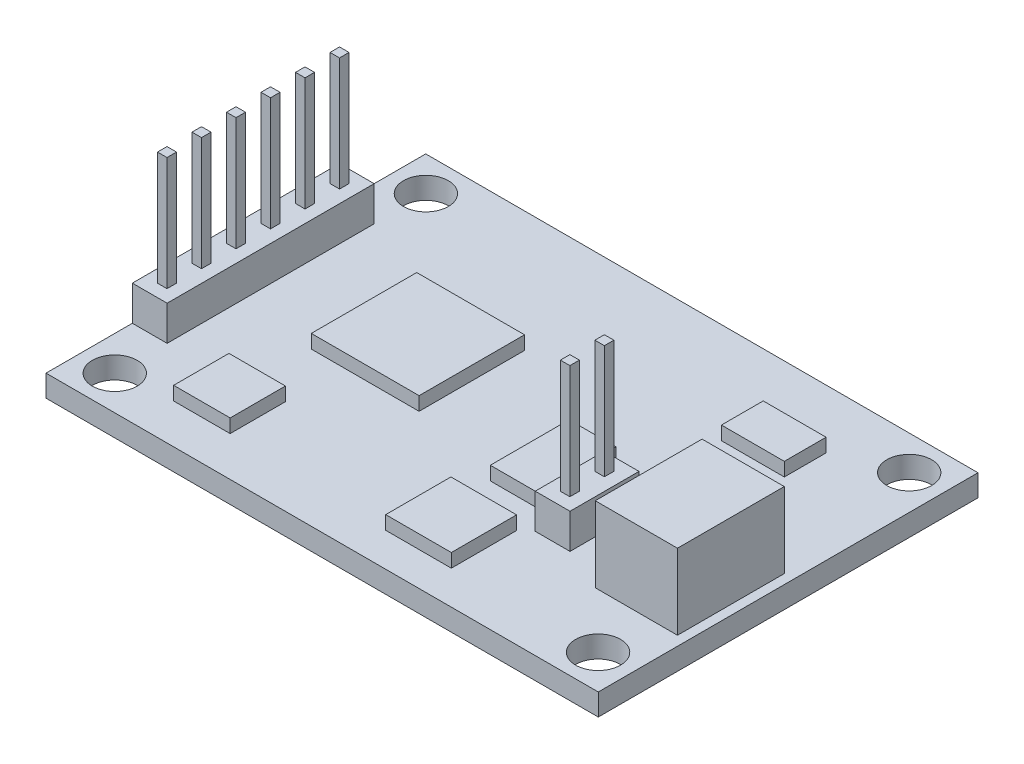
from build123d import *

# Parameters (mm, degrees)
SKETCH1_W             = 40.65
SKETCH1_H             = 27.95
SKETCH1_R             = 1.65
BOSS_EXTRUDE1_DEPTH   = 1.6
SKETCH2_W             = 2.56
SKETCH2_H             = 15.24
BOSS_EXTRUDE2_DEPTH   = 2.56
SKETCH2_H_2           = 5.08
BOSS_EXTRUDE2_2_DEPTH = 2.56
SKETCH3_W             = 0.7
SKETCH3_H             = 0.7
BOSS_EXTRUDE3_DEPTH   = 8.36
SKETCH4_W             = 7.935378233
SKETCH4_H             = 7.759687203
SKETCH4_W_2           = 4.158021067
SKETCH4_H_2           = 4.070175552
SKETCH4_W_3           = 4.831503353
SKETCH4_H_3           = 4.802221514
SKETCH4_W_4           = 3.455256943
SKETCH4_H_4           = 5.797804023
SKETCH4_W_5           = 4.626530483
SKETCH4_H_5           = 3.074593043
BOSS_EXTRUDE4_DEPTH   = 1
SKETCH5_W             = 6.05
SKETCH5_H             = 7.86
BOSS_EXTRUDE5_DEPTH   = 5.55


with BuildPart() as part:
    # Sketch1 → Boss-Extrude1 (new body)
    with BuildSketch(Plane(origin=(0, 0, 0), x_dir=(1, 0, 0), z_dir=(0, 1, 0))):
        Rectangle(SKETCH1_W, SKETCH1_H)
        with Locations((17.7875, 11.45)):
            Circle(SKETCH1_R, mode=Mode.SUBTRACT)
        with Locations((-17.7875, 11.45)):
            Circle(SKETCH1_R, mode=Mode.SUBTRACT)
        with Locations((17.7875, -11.45)):
            Circle(SKETCH1_R, mode=Mode.SUBTRACT)
        with Locations((-17.7875, -11.45)):
            Circle(SKETCH1_R, mode=Mode.SUBTRACT)
    extrude(amount=BOSS_EXTRUDE1_DEPTH)

    # Sketch4 → Boss-Extrude4 (add)
    with BuildSketch(Plane(origin=(0, 1.6, 0), x_dir=(1, 0, 0), z_dir=(0, 1, 0))):
        with Locations((-8.125710184, 1.200555378)):
            Rectangle(SKETCH4_W, SKETCH4_H)
        with Locations((-11.771299077, -9.018806258)):
            Rectangle(SKETCH4_W_2, SKETCH4_H_2)
        with Locations((4.611889564, -9.092010854)):
            Rectangle(SKETCH4_W_3, SKETCH4_H_3)
        with Locations((4.626530483, -1.595860199)):
            Rectangle(SKETCH4_W_4, SKETCH4_H_4)
        with Locations((11.156380469, 8.111069265)):
            Rectangle(SKETCH4_W_5, SKETCH4_H_5)
    extrude(amount=BOSS_EXTRUDE4_DEPTH)

    # Sketch5 → Boss-Extrude5 (add)
    with BuildSketch(Plane(origin=(0, 1.6, 0), x_dir=(1, 0, 0), z_dir=(0, 1, 0))):
        with Locations((16.6, -3.515)):
            Rectangle(SKETCH5_W, SKETCH5_H)
    extrude(amount=BOSS_EXTRUDE5_DEPTH)


with BuildPart() as body_2:
    # Sketch2 → Boss-Extrude2 (new body)
    with BuildSketch(Plane(origin=(0, 1.6, 0), x_dir=(1, 0, 0), z_dir=(0, 1, 0))):
        with Locations((-19.045, 0)):
            Rectangle(SKETCH2_W, SKETCH2_H)
    extrude(amount=BOSS_EXTRUDE2_DEPTH)



with BuildPart() as body_3:
    # Sketch2 → Boss-Extrude2 2 (new body)
    with BuildSketch(Plane(origin=(0, 1.6, 0), x_dir=(1, 0, 0), z_dir=(0, 1, 0))):
        with Locations((9.045, -3.515)):
            Rectangle(SKETCH2_W, SKETCH2_H_2)
    extrude(amount=BOSS_EXTRUDE2_2_DEPTH)


with BuildPart() as body_2_1:
    add(body_2.part)

    add(body_3.part)  # Boss-Extrude3 merges body 3
    # Sketch3 → Boss-Extrude3 (add)
    with BuildSketch(Plane(origin=(0, 4.16, 0), x_dir=(1, 0, 0), z_dir=(0, 1, 0))):
        with Locations((-19.045, 3.81)):
            Rectangle(SKETCH3_W, SKETCH3_H)
        with Locations((-19.045, 6.35)):
            Rectangle(SKETCH3_W, SKETCH3_H)
        with Locations((-19.045, 1.27)):
            Rectangle(SKETCH3_W, SKETCH3_H)
        with Locations((-19.045, -1.27)):
            Rectangle(SKETCH3_W, SKETCH3_H)
        with Locations((-19.045, -3.81)):
            Rectangle(SKETCH3_W, SKETCH3_H)
        with Locations((-19.045, -6.35)):
            Rectangle(SKETCH3_W, SKETCH3_H)
        with Locations((9.045, -2.245)):
            Rectangle(SKETCH3_W, SKETCH3_H)
        with Locations((9.045, -4.785)):
            Rectangle(SKETCH3_W, SKETCH3_H)
    extrude(amount=BOSS_EXTRUDE3_DEPTH)


solid = Compound([part.part, body_2_1.part])
